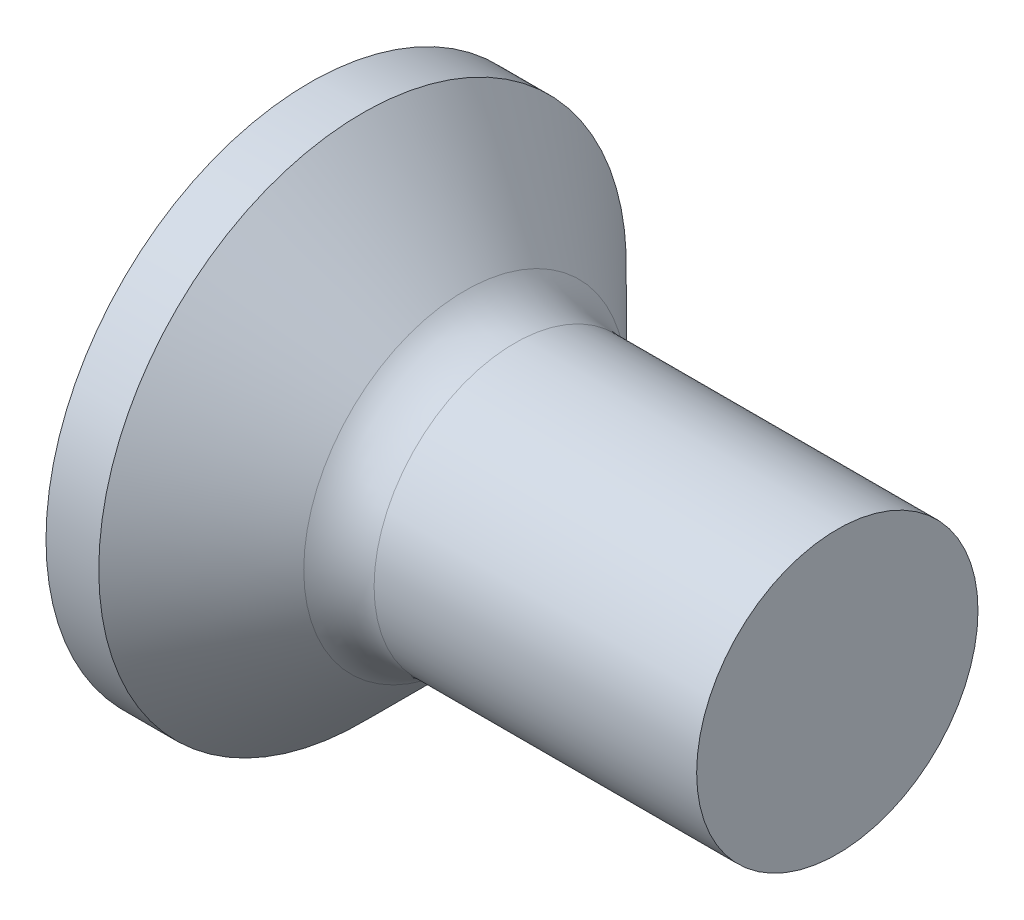
from build123d import *

# Parameters (mm, degrees)
FILLET1_R    = 0.4
SKETCH3_W    = 0.48
SKETCH3_H    = 1.9
SKETCH4_W    = 0.48
SKETCH4_H    = 0.703404182
RECPAT_COUNT = 2
RECPAT_ANGLE = 90


with BuildPart() as part:
    # BodySke → Base-Revolve (revolve)
    with BuildSketch(Plane.XY):
        with BuildLine():
            Line((0, 0), (3.4, 0))
            Line((3.4, 0), (3.4, 0.8))
            Line((3.4, 0.8), (1.4, 0.8))
            Line((1.4, 0.8), (0.7, 1.5))
            Line((0.7, 1.5), (0.4, 1.5))
            ThreePointArc((0.4, 1.5), (0.101717244, 0.776208735), (0, 0))
        make_face()
    revolve(axis=Axis((-15.875, 0, 0), (1, 0, 0)))

    # Fillet1
    fillet1_edges = [part.edges().sort_by_distance(p)[0] for p in [
        (1.4, -0.8, 0),
    ]]
    fillet(fillet1_edges, radius=FILLET1_R)

    # Sketch3 → Recess section 0
    with BuildSketch(Plane(origin=(0, 0, 0), x_dir=(0, 0, -1), z_dir=(1, 0, 0))):
        Rectangle(SKETCH3_W, SKETCH3_H)
    # Sketch4 → Recess section 1
    with BuildSketch(Plane(origin=(1.2, 0, 0), x_dir=(0, 0, -1), z_dir=(1, 0, 0))):
        Rectangle(SKETCH4_W, SKETCH4_H)
    recess = loft(mode=Mode.SUBTRACT)

    # RecPat: Recess ×2 about axis
    recpat_axis = Axis((0, 0, 0), (1, 0, 0))
    for i in range(1, RECPAT_COUNT):
        add(recess.rotate(recpat_axis, i * RECPAT_ANGLE / (RECPAT_COUNT - 1)), mode=Mode.SUBTRACT)

    # RecCorSke → RecessCore (revolve, cut)
    with BuildSketch(Plane.XY):
        Polygon((0, 0), (0, 0.439412174), (1.2, 0.3555), (1.315508952, 0), align=None)
    revolve(axis=Axis((-3.175, 0, 0), (1, 0, 0)), mode=Mode.SUBTRACT)


solid = part.part
